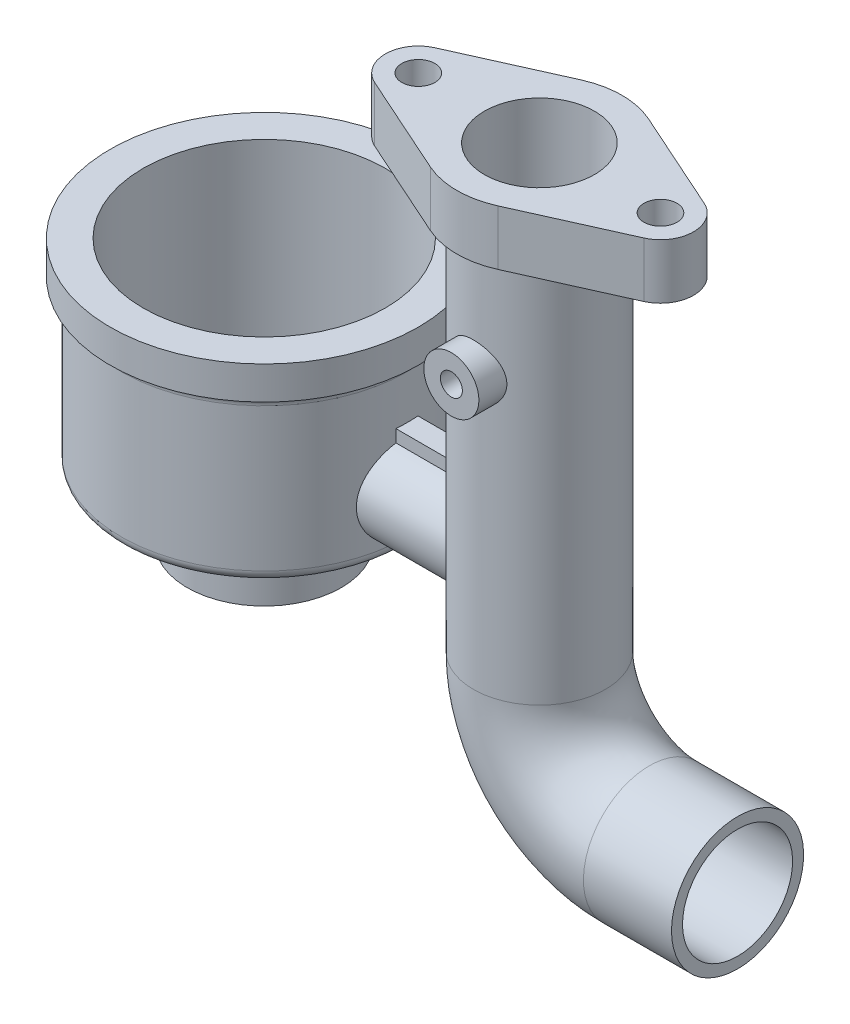
from build123d import *

# Parameters (mm, degrees)
BOSS_EXTRUDE1_REACH      = 38
BOSS_EXTRUDE1_END_RADIUS = 13
SWEEP1_PROFILE_R         = 6
CUT_SWEEP1_PROFILE_R     = 5
CUT_EXTRUDE7_REACH       = 38
CUT_EXTRUDE7_END_RADIUS  = 11
SKETCH111_R              = 1
SKETCH112_R              = 5
SKETCH112_R_2            = 1.5
BOSS_EXTRUDE2_DEPTH      = 5
BOSS_EXTRUDE3_REACH      = 24
BOSS_EXTRUDE3_END_RADIUS = 6
SKETCH113_R              = 2.5
CUT_EXTRUDE8_REACH       = 24
CUT_EXTRUDE8_END_RADIUS  = 5
SKETCH114_R              = 1


with BuildPart() as part:
    # Sketch1 → Revolve1 (revolve)
    with BuildSketch(Plane.XY):
        with BuildLine():
            Line((11, 8), (11, 24))
            Line((11, 24), (14, 24))
            Line((14, 24), (14, 21))
            ThreePointArc((14, 21), (13.292893219, 20.707106781), (13, 20))
            Line((13, 20), (13, 7))
            ThreePointArc((13, 7), (12.707106781, 6.292893219), (12, 6))
            Line((12, 6), (3, 6))
            Line((3, 6), (3, 3))
            Line((3, 3), (7, 3))
            Line((7, 3), (7, 0))
            Line((7, 0), (1, 0))
            Line((1, 0), (1, 8))
            Line((1, 8), (11, 8))
        make_face()
    revolve(axis=Axis((0, -17.809326976, 0), (0, 1, 0)))

    # Boss-Extrude1: up to this cylinder (the profile starts outside it)
    boss_extrude1_end = Plane(origin=(0, 11.178288, 0), z_dir=(0, -1, 0)) * Cylinder(BOSS_EXTRUDE1_END_RADIUS, 103, mode=Mode.PRIVATE)
    # Sketch43 → Boss-Extrude1 (add, up to the surface)
    with BuildSketch(Plane(origin=(22, 0, 0), x_dir=(0, 0, -1), z_dir=(1, 0, 0)), mode=Mode.PRIVATE) as boss_extrude1_sk1:
        with BuildLine():
            Line((-1, 16), (1, 16))
            Line((1, 16), (1, 14.872983346))
            ThreePointArc((1, 14.872983346), (0, 7), (-1, 14.872983346))
            Line((-1, 14.872983346), (-1, 16))
        make_face()
    boss_extrude1_tool1 = extrude(boss_extrude1_sk1.sketch, amount=-BOSS_EXTRUDE1_REACH, mode=Mode.PRIVATE) - boss_extrude1_end
    add(boss_extrude1_tool1.solids().sort_by_distance((22, 11.178288, 0))[0])

    # Sweep1: sweep along a path in Sketch45
    with BuildLine(Plane.XY) as sweep1_path:
        Line((25, 39), (25, 4))
        ThreePointArc((25, 4), (27.928932188, -3.071067812), (35, -6))
        Line((35, -6), (43, -6))
    # Sweep1 profile (on start of the path) → Sweep1 (sweep)
    with BuildSketch(Plane(origin=(25, 39, 0), x_dir=(0, 0, -1), z_dir=(0, -1, 0))):
        Circle(SWEEP1_PROFILE_R)
    sweep(path=sweep1_path.line)

    # Cut-Sweep1: sweep along a path in Sketch45_2
    with BuildLine(Plane.XY) as cut_sweep1_path:
        Line((25, 39), (25, 4))
        ThreePointArc((25, 4), (27.928932188, -3.071067812), (35, -6))
        Line((35, -6), (43, -6))
    # Cut-Sweep1 profile (on start of the path) → Cut-Sweep1 (sweep, cut)
    with BuildSketch(Plane(origin=(25, 39, 0), x_dir=(0, 0, -1), z_dir=(0, -1, 0))):
        Circle(CUT_SWEEP1_PROFILE_R)
    sweep(path=cut_sweep1_path.line, mode=Mode.SUBTRACT)

    # Cut-Extrude7: up to this cylinder (the profile starts outside it)
    cut_extrude7_end = Plane(origin=(0, 11, 0), z_dir=(0, -1, 0)) * Cylinder(CUT_EXTRUDE7_END_RADIUS, 99, mode=Mode.PRIVATE)
    # Sketch111 → Cut-Extrude7 (cut, up to the surface)
    with BuildSketch(Plane(origin=(22, 0, 0), x_dir=(0, 0, -1), z_dir=(1, 0, 0)), mode=Mode.PRIVATE) as cut_extrude7_sk1:
        with Locations((0, 11)):
            Circle(SKETCH111_R)
    cut_extrude7_tool1 = extrude(cut_extrude7_sk1.sketch, amount=-CUT_EXTRUDE7_REACH, mode=Mode.PRIVATE) - cut_extrude7_end
    add(cut_extrude7_tool1.solids().sort_by_distance((22, 11, 0))[0], mode=Mode.SUBTRACT)

    # Sketch112 → Boss-Extrude2 (add)
    with BuildSketch(Plane(origin=(0, 39, 0), x_dir=(1, 0, 0), z_dir=(0, 1, 0))):
        with BuildLine():
            Line((37.227272727, 2.737480895), (28.068181818, 6.843702239))
            ThreePointArc((28.068181818, 6.843702239), (25, 7.5), (21.931818182, 6.843702239))
            Line((21.931818182, 6.843702239), (12.772727273, 2.737480895))
            ThreePointArc((12.772727273, 2.737480895), (11, 0), (12.772727273, -2.737480895))
            Line((12.772727273, -2.737480895), (21.931818182, -6.843702239))
            ThreePointArc((21.931818182, -6.843702239), (25, -7.5), (28.068181818, -6.843702239))
            Line((28.068181818, -6.843702239), (37.227272727, -2.737480895))
            ThreePointArc((37.227272727, -2.737480895), (39, 0), (37.227272727, 2.737480895))
        make_face()
        with Locations(Location((25, 0, 0), (0, 0, 180))):  # turned: the seam where the file's is
            Circle(SKETCH112_R, mode=Mode.SUBTRACT)
        with Locations(Location((36, 0, 0), (0, 0, 270))):  # turned: the seam where the file's is
            Circle(SKETCH112_R_2, mode=Mode.SUBTRACT)
        with Locations(Location((14, 0, 0), (0, 0, 270))):  # turned: the seam where the file's is
            Circle(SKETCH112_R_2, mode=Mode.SUBTRACT)
    extrude(amount=BOSS_EXTRUDE2_DEPTH)

    # Boss-Extrude3: up to this cylinder (the profile starts outside it)
    boss_extrude3_end = Plane(origin=(25, 29, 0), z_dir=(0, -1, 0)) * Cylinder(BOSS_EXTRUDE3_END_RADIUS, 61, mode=Mode.PRIVATE)
    # Sketch113 → Boss-Extrude3 (add, up to the surface)
    with BuildSketch(Plane.XY.offset(8), mode=Mode.PRIVATE) as boss_extrude3_sk1:
        with Locations((25, 29)):
            Circle(SKETCH113_R)
    boss_extrude3_tool1 = extrude(boss_extrude3_sk1.sketch, amount=-BOSS_EXTRUDE3_REACH, mode=Mode.PRIVATE) - boss_extrude3_end
    add(boss_extrude3_tool1.solids().sort_by_distance((25, 29, 8))[0])

    # Cut-Extrude8: up to this cylinder (the profile starts outside it)
    cut_extrude8_end = Plane(origin=(25, 29, 0), z_dir=(0, -1, 0)) * Cylinder(CUT_EXTRUDE8_END_RADIUS, 59, mode=Mode.PRIVATE)
    # Sketch114 → Cut-Extrude8 (cut, up to the surface)
    with BuildSketch(Plane.XY.offset(8), mode=Mode.PRIVATE) as cut_extrude8_sk1:
        with Locations((25, 29)):
            Circle(SKETCH114_R)
    cut_extrude8_tool1 = extrude(cut_extrude8_sk1.sketch, amount=-CUT_EXTRUDE8_REACH, mode=Mode.PRIVATE) - cut_extrude8_end
    add(cut_extrude8_tool1.solids().sort_by_distance((25, 29, 8))[0], mode=Mode.SUBTRACT)


solid = part.part
